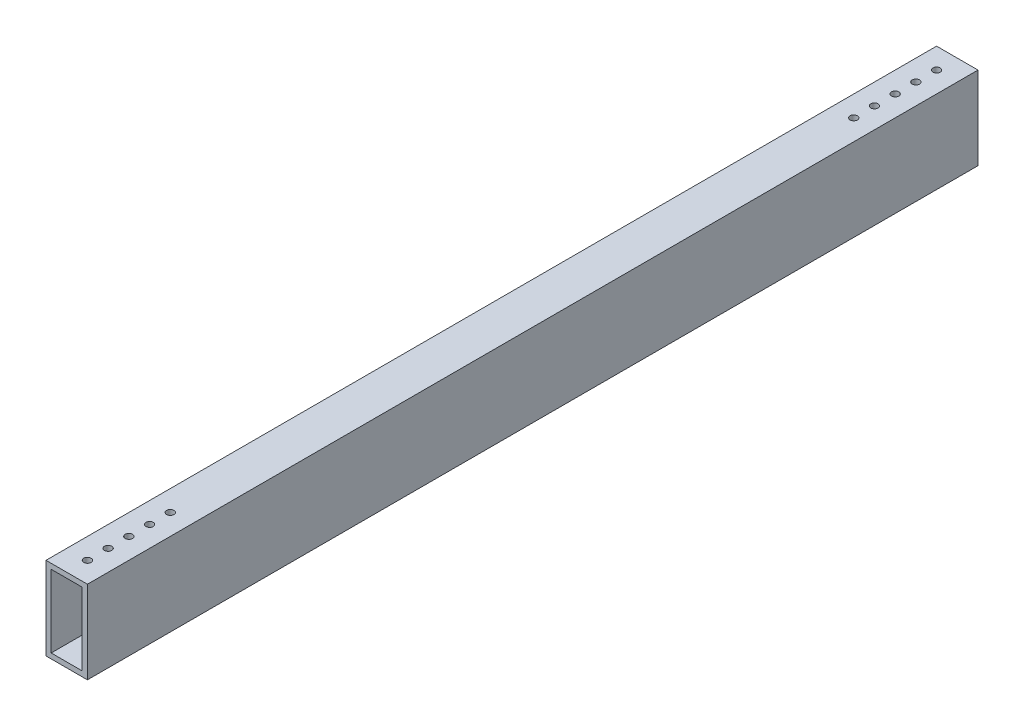
from build123d import *

# Parameters (mm, degrees)
SKETCH1_W           = 25.4
SKETCH1_H           = 50.8
SKETCH1_W_2         = 19.05
SKETCH1_H_2         = 44.45
BOSS_EXTRUDE1_DEPTH = 273.05
SKETCH2_R           = 2.2479
CUT_EXTRUDE5_DEPTH  = 3.175
CUT_EXTRUDE9_START  = 3.175
SKETCH2_5_R         = 2.2479
CUT_EXTRUDE9_DEPTH  = 48.625


with BuildPart() as part:
    # Sketch1 → Boss-Extrude1 (new body, symmetric)
    with BuildSketch(Plane.XY):
        with Locations((12.7, 25.4)):
            Rectangle(SKETCH1_W, SKETCH1_H)
        with Locations((12.7, 25.4)):
            Rectangle(SKETCH1_W_2, SKETCH1_H_2, mode=Mode.SUBTRACT)
    extrude(amount=BOSS_EXTRUDE1_DEPTH, both=True)

    # Sketch2 → Cut-Extrude5 (cut)
    with BuildSketch(Plane(origin=(0, 0, 0), x_dir=(1, 0, 0), z_dir=(0, 1, 0))):
        with Locations((12.7, 260.35)):
            Circle(SKETCH2_R)
        with Locations((12.7, 234.95)):
            Circle(SKETCH2_R)
        with Locations((12.7, 209.55)):
            Circle(SKETCH2_R)
    cut_extrude5 = extrude(amount=CUT_EXTRUDE5_DEPTH, mode=Mode.SUBTRACT)

    # Sketch2_5 → Cut-Extrude9 (cut, through all)
    with BuildSketch(Plane(origin=(0, 0, 0), x_dir=(1, 0, 0), z_dir=(0, 1, 0)).offset(CUT_EXTRUDE9_START)):
        with Locations((12.7, 260.35)):
            Circle(SKETCH2_5_R)
        with Locations((12.7, 247.65)):
            Circle(SKETCH2_5_R)
        with Locations((12.7, 234.95)):
            Circle(SKETCH2_5_R)
        with Locations((12.7, 222.25)):
            Circle(SKETCH2_5_R)
        with Locations((12.7, 209.55)):
            Circle(SKETCH2_5_R)
    cut_extrude9 = extrude(amount=CUT_EXTRUDE9_DEPTH, mode=Mode.SUBTRACT)

    # Mirror3: Cut-Extrude5, Cut-Extrude9 across plane
    add(cut_extrude5.mirror(Plane.XY), mode=Mode.SUBTRACT)
    add(cut_extrude9.mirror(Plane.XY), mode=Mode.SUBTRACT)


solid = part.part
